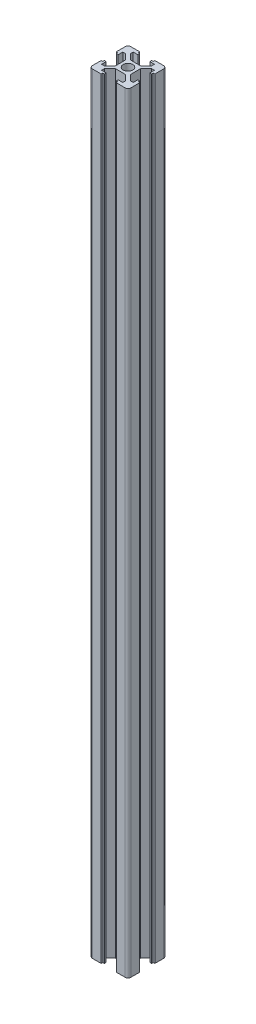
from build123d import *

# Parameters (mm, degrees)
SKETCH1_R           = 2.5
BOSS_EXTRUDE1_DEPTH = 400


with BuildPart() as part:
    # Sketch1 → Boss-Extrude1 (new body)
    with BuildSketch(Plane(origin=(0, 0, 0), x_dir=(1, 0, 0), z_dir=(0, 1, 0))):
        with BuildLine():
            Line((3.9, 10), (8.5, 10))
            ThreePointArc((8.5, 10), (9.560660172, 9.560660172), (10, 8.5))
            Line((10, 8.5), (10, 3.9))
            Line((10, 3.9), (9.2, 3.9))
            Line((9.2, 3.9), (9.2, 3.1))
            Line((9.2, 3.1), (8.2, 3.1))
            Line((8.2, 3.1), (8.2, 5.5))
            Line((8.2, 5.5), (6.77, 5.5))
            Line((6.77, 5.5), (3.9, 2.63))
            Line((3.9, 2.63), (3.9, 0))
            Line((3.9, 0), (3.9, -2.63))
            Line((3.9, -2.63), (6.77, -5.5))
            Line((6.77, -5.5), (8.2, -5.5))
            Line((8.2, -5.5), (8.2, -3.1))
            Line((8.2, -3.1), (9.2, -3.1))
            Line((9.2, -3.1), (9.2, -3.9))
            Line((9.2, -3.9), (10, -3.9))
            Line((10, -3.9), (10, -8.5))
            ThreePointArc((10, -8.5), (9.560660172, -9.560660172), (8.5, -10))
            Line((8.5, -10), (3.9, -10))
            Line((3.9, -10), (3.9, -9.2))
            Line((3.9, -9.2), (3.1, -9.2))
            Line((3.1, -9.2), (3.1, -8.2))
            Line((3.1, -8.2), (5.5, -8.2))
            Line((5.5, -8.2), (5.5, -6.77))
            Line((5.5, -6.77), (2.63, -3.9))
            Line((2.63, -3.9), (0, -3.9))
            Line((0, -3.9), (-2.63, -3.9))
            Line((-2.63, -3.9), (-5.5, -6.77))
            Line((-5.5, -6.77), (-5.5, -8.2))
            Line((-5.5, -8.2), (-3.1, -8.2))
            Line((-3.1, -8.2), (-3.1, -9.2))
            Line((-3.1, -9.2), (-3.9, -9.2))
            Line((-3.9, -9.2), (-3.9, -10))
            Line((-3.9, -10), (-8.5, -10))
            ThreePointArc((-8.5, -10), (-9.560660172, -9.560660172), (-10, -8.5))
            Line((-10, -8.5), (-10, -3.9))
            Line((-10, -3.9), (-9.2, -3.9))
            Line((-9.2, -3.9), (-9.2, -3.1))
            Line((-9.2, -3.1), (-8.2, -3.1))
            Line((-8.2, -3.1), (-8.2, -5.5))
            Line((-8.2, -5.5), (-6.77, -5.5))
            Line((-6.77, -5.5), (-3.9, -2.63))
            Line((-3.9, -2.63), (-3.9, 0))
            Line((-3.9, 0), (-3.9, 2.63))
            Line((-3.9, 2.63), (-6.77, 5.5))
            Line((-6.77, 5.5), (-8.2, 5.5))
            Line((-8.2, 5.5), (-8.2, 3.1))
            Line((-8.2, 3.1), (-9.2, 3.1))
            Line((-9.2, 3.1), (-9.2, 3.9))
            Line((-9.2, 3.9), (-10, 3.9))
            Line((-10, 3.9), (-10, 8.5))
            ThreePointArc((-10, 8.5), (-9.560660172, 9.560660172), (-8.5, 10))
            Line((-8.5, 10), (-3.9, 10))
            Line((-3.9, 10), (-3.9, 9.2))
            Line((-3.9, 9.2), (-3.1, 9.2))
            Line((-3.1, 9.2), (-3.1, 8.2))
            Line((-3.1, 8.2), (-5.5, 8.2))
            Line((-5.5, 8.2), (-5.5, 6.77))
            Line((-5.5, 6.77), (-2.63, 3.9))
            Line((-2.63, 3.9), (2.63, 3.9))
            Line((2.63, 3.9), (5.5, 6.77))
            Line((5.5, 6.77), (5.5, 8.2))
            Line((5.5, 8.2), (3.1, 8.2))
            Line((3.1, 8.2), (3.1, 9.2))
            Line((3.1, 9.2), (3.9, 9.2))
            Line((3.9, 9.2), (3.9, 10))
        make_face()
        Circle(SKETCH1_R, mode=Mode.SUBTRACT)
    extrude(amount=BOSS_EXTRUDE1_DEPTH)


solid = part.part
